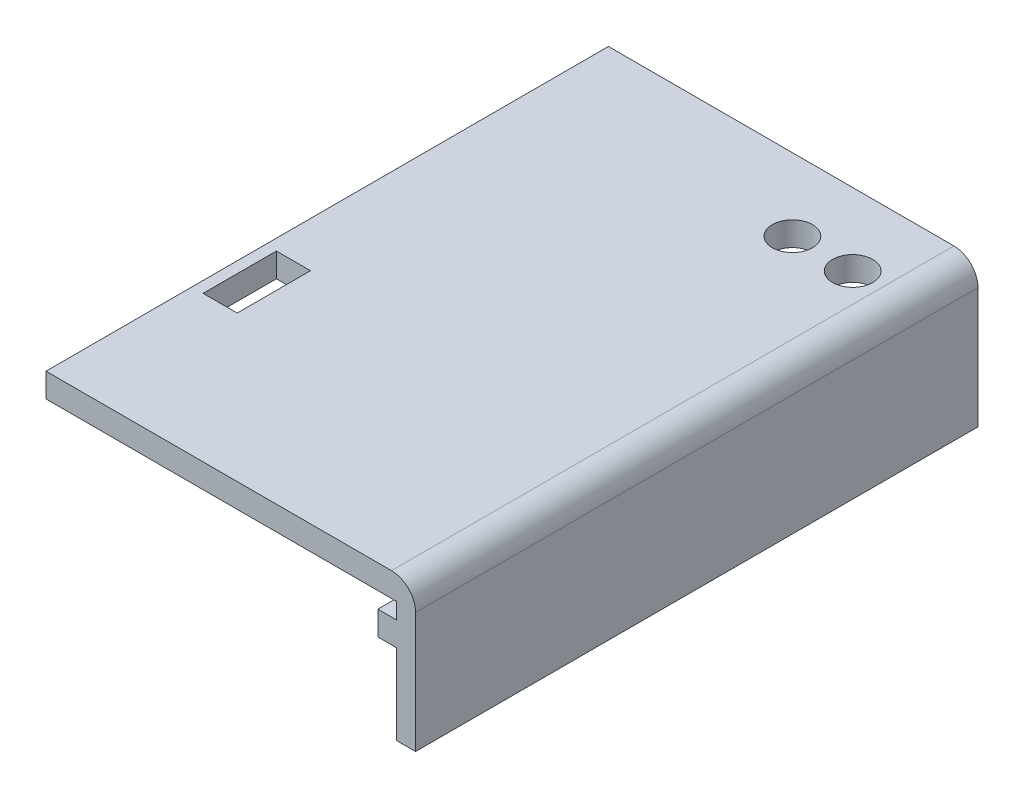
from build123d import *

# Parameters (mm, degrees)
EXTRUDE1_DEPTH     = 70
SKETCH2_W          = 3
SKETCH2_H          = 3
EXTRUDE2_DEPTH     = 2.3
SKETCH3_W          = 4
SKETCH3_H          = 5
EXTRUDE3_DEPTH     = 2
SKETCH4_R          = 1
EXTRUDE4_DEPTH     = 5
FILLET1_R          = 3
SKETCH5_R          = 2.5
EXTRUDE6_DEPTH     = 5
SKETCH6_W          = 4.247308601
SKETCH6_H          = 9.124947865
CUT_EXTRUDE1_DEPTH = 10


with BuildPart() as part:
    # Sketch1 → Extrude1 (new body)
    with BuildSketch(Plane.XY):
        Polygon((-23, 9), (23, 9), (23, -9), (20.6, -9), (20.6, 6), (-23, 6), align=None)
    extrude(amount=EXTRUDE1_DEPTH)

    # Sketch2 → Extrude2 (add)
    with BuildSketch(Plane.ZY.offset(-20.6)):
        with Locations((1.5, 2.5)):
            Rectangle(SKETCH2_W, SKETCH2_H)
        with Locations((68.5, 2.5)):
            Rectangle(SKETCH2_W, SKETCH2_H)
    extrude(amount=EXTRUDE2_DEPTH)

    # Sketch3 → Extrude3 (add)
    with BuildSketch(Plane.XZ.offset(-6)):
        with Locations((-21, 8)):
            Rectangle(SKETCH3_W, SKETCH3_H)
        with Locations((-21, 62)):
            Rectangle(SKETCH3_W, SKETCH3_H)
    extrude(amount=EXTRUDE3_DEPTH)

    # Sketch4 → Extrude4 (cut)
    with BuildSketch(Plane.ZY.offset(23)):
        with Locations((8, 6.75)):
            Circle(SKETCH4_R)
        with Locations((62, 6.75)):
            Circle(SKETCH4_R)
    extrude(amount=-EXTRUDE4_DEPTH, mode=Mode.SUBTRACT)

    # Fillet1
    fillet1_edges = [part.edges().sort_by_distance(p)[0] for p in [
        (23, 9, 35),
    ]]
    fillet(fillet1_edges, radius=FILLET1_R)

    # Sketch5 → Extrude6 (cut)
    with BuildSketch(Plane(origin=(0, 9, 0), x_dir=(-1, 0, 0), z_dir=(0, 1, 0))):
        with Locations((-16.4, 9)):
            Circle(SKETCH5_R)
        with Locations((-8.9, 9)):
            Circle(SKETCH5_R)
    extrude(amount=-EXTRUDE6_DEPTH, mode=Mode.SUBTRACT)

    # Sketch6 → Cut-Extrude1 (cut)
    with BuildSketch(Plane(origin=(0, 9, 0), x_dir=(-1, 0, 0), z_dir=(0, 1, 0))):
        with Locations((19.489700301, 47.273609058)):
            Rectangle(SKETCH6_W, SKETCH6_H)
    extrude(amount=-CUT_EXTRUDE1_DEPTH, mode=Mode.SUBTRACT)


solid = part.part
